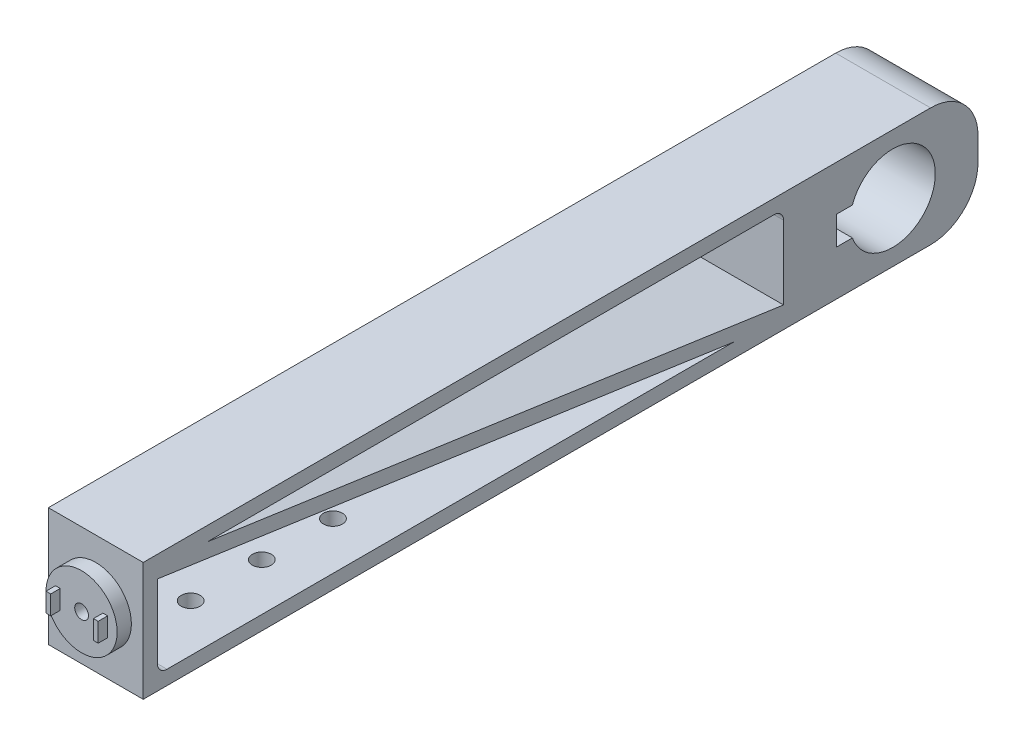
from build123d import *

# Parameters (mm, degrees)
SKETCH2_W           = 132
SKETCH2_H           = 19
BOSS_EXTRUDE1_DEPTH = 20
SKETCH3_R           = 7.5
BOSS_EXTRUDE2_DEPTH = 3
SKETCH4_W           = 1
SKETCH4_H           = 4
BOSS_EXTRUDE3_DEPTH = 2
CUT_EXTRUDE1_REACH  = 181
SKETCH5_R           = 1.45
FILLET1_R           = 2
SKETCH6_R           = 2
CUT_EXTRUDE2_DEPTH  = 10


with BuildPart() as part:
    # Sketch2 → Boss-Extrude1 (new body)
    with BuildSketch(Plane(origin=(0, 0, 0), x_dir=(0, 0, -1), z_dir=(1, 0, 0))):
        with BuildLine():
            Line((88, 2.5), (88, -2.5))
            ThreePointArc((88, -2.5), (85.071067812, -9.571067812), (78, -12.5))
            Line((78, -12.5), (-88, -12.5))
            Line((-88, -12.5), (-88, -9.5))
            Line((-88, -9.5), (-88, 9.5))
            Line((-88, 9.5), (-88, 12.5))
            Line((-88, 12.5), (78, 12.5))
            ThreePointArc((78, 12.5), (85.071067812, 9.571067812), (88, 2.5))
        make_face()
        with BuildLine():
            ThreePointArc((61.514718626, -3), (79, 0), (61.514718626, 3))
            Line((61.514718626, 3), (58.2, 3))
            Line((58.2, 3), (58.2, -3))
            Line((58.2, -3), (61.514718626, -3))
        make_face(mode=Mode.SUBTRACT)
        with Locations((-19, 0)):
            Rectangle(SKETCH2_W, SKETCH2_H, mode=Mode.SUBTRACT)
        Polygon((-85, 7.984540751), (36.47154627, -9.5), (47, -9.5), (47, -7.984540751), (-74.47154627, 9.5), (-85, 9.5), align=None)
    extrude(amount=BOSS_EXTRUDE1_DEPTH)

    # Sketch3 → Boss-Extrude2 (add)
    with BuildSketch(Plane.XY.offset(88)):
        with Locations((10, 0)):
            Circle(SKETCH3_R)
    extrude(amount=BOSS_EXTRUDE2_DEPTH)

    # Sketch4 → Boss-Extrude3 (add)
    with BuildSketch(Plane.XY.offset(91)):
        with Locations((5, 0)):
            Rectangle(SKETCH4_W, SKETCH4_H)
        with Locations((15, 0)):
            Rectangle(SKETCH4_W, SKETCH4_H)
    extrude(amount=BOSS_EXTRUDE3_DEPTH)

    # Sketch5 → Cut-Extrude1 (cut, up to next)
    with BuildSketch(Plane.XY.offset(91), mode=Mode.PRIVATE) as cut_extrude1_sk1:
        with Locations((10, 0)):
            Circle(SKETCH5_R)
    cut_extrude1_tool1 = extrude(cut_extrude1_sk1.sketch, amount=-CUT_EXTRUDE1_REACH, mode=Mode.PRIVATE) & part.part
    add(cut_extrude1_tool1.solids().sort_by_distance((10, 0, 91))[0], mode=Mode.SUBTRACT)

    # Fillet1
    fillet1_edges = [part.edges().sort_by_distance(p)[0] for p in [
        (10, 9.5, -47),
        (10, -9.5, 85),
    ]]
    fillet(fillet1_edges, radius=FILLET1_R)

    # Sketch6 → Cut-Extrude2 (cut)
    with BuildSketch(Plane(origin=(0, -9.5, 0), x_dir=(1, 0, 0), z_dir=(0, 1, 0))):
        with Locations((10, -53)):
            Circle(SKETCH6_R)
        with Locations((10, -68)):
            Circle(SKETCH6_R)
        with Locations((10, -38)):
            Circle(SKETCH6_R)
    extrude(amount=-CUT_EXTRUDE2_DEPTH, mode=Mode.SUBTRACT)


solid = part.part
